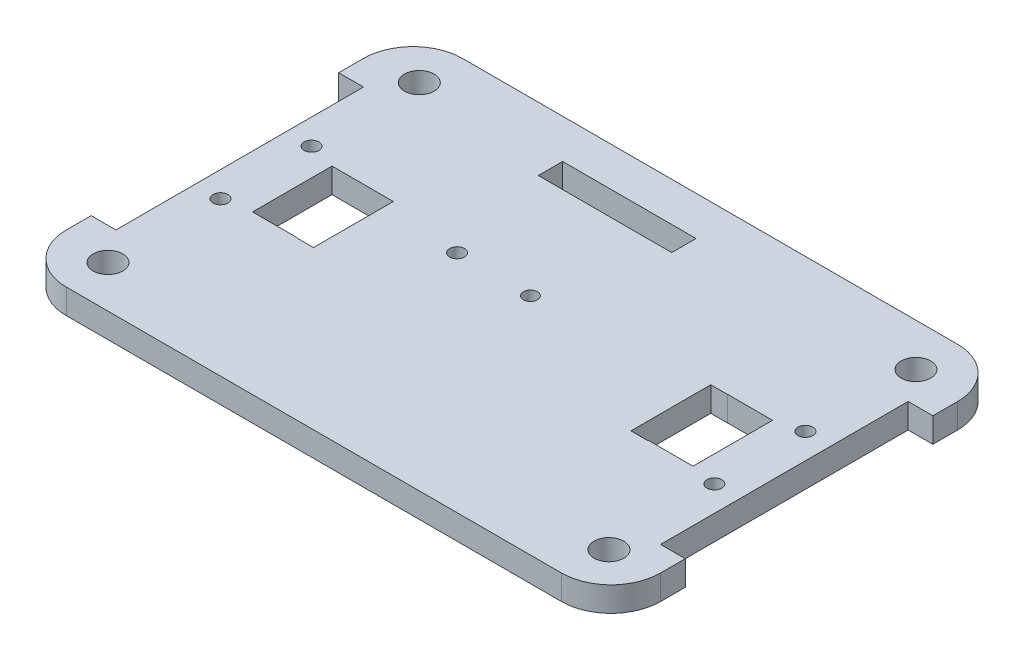
from build123d import *

# Parameters (mm, degrees)
BOSS_EXTRUDE1_DEPTH = 5
SKETCH2_R           = 3
SKETCH2_R_2         = 3.002001364
SKETCH2_R_3         = 2.999925667
SKETCH2_R_4         = 2.998527559
CUT_EXTRUDE2_DEPTH  = 5
SKETCH6_W           = 9.011632363
SKETCH6_H           = 16.045928836
SKETCH6_W_2         = 9.056347314
SKETCH6_H_2         = 16.054931831
CUT_EXTRUDE4_DEPTH  = 5
SKETCH8_R           = 1.49722604
SKETCH8_R_2         = 1.420293569
CUT_EXTRUDE6_DEPTH  = 5
SKETCH16_W          = 26.950881965
SKETCH16_H          = 4.917135509
CUT_EXTRUDE9_DEPTH  = 5
SKETCH11_R          = 1.497426658
SKETCH11_W          = 3.370796783
SKETCH11_H          = 16.122720009
CUT_EXTRUDE10_DEPTH = 10
SKETCH18_W          = 2.969435554
SKETCH18_H          = 16.028197631
CUT_EXTRUDE11_DEPTH = 10


with BuildPart() as part:
    # Sketch1 → Boss-Extrude1 (new body)
    with BuildSketch(Plane(origin=(0, 0, 0), x_dir=(1, 0, 0), z_dir=(0, 1, 0))):
        with BuildLine():
            Line((10, 0), (110, 0))
            ThreePointArc((110, 0), (117.071067812, -2.928932188), (120, -10))
            Line((120, -10), (120, -15))
            Line((120, -15), (115, -15))
            Line((115, -15), (115, -65))
            Line((115, -65), (120, -65))
            Line((120, -65), (120, -70))
            ThreePointArc((120, -70), (117.071067812, -77.071067812), (110, -80))
            Line((110, -80), (10, -80))
            ThreePointArc((10, -80), (2.928932188, -77.071067812), (0, -70))
            Line((0, -70), (0, -65))
            Line((0, -65), (5, -65))
            Line((5, -65), (5, -15))
            Line((5, -15), (0, -15))
            Line((0, -15), (0, -10))
            ThreePointArc((0, -10), (2.928932188, -2.928932188), (10, 0))
        make_face()
    extrude(amount=BOSS_EXTRUDE1_DEPTH)

    # Sketch2 → Cut-Extrude2 (cut)
    with BuildSketch(Plane(origin=(0, 5, 0), x_dir=(1, 0, 0), z_dir=(0, 1, 0))):
        with Locations((9.871405569, -8.58955783)):
            Circle(SKETCH2_R)
        with Locations((9.87978839, -71.481609293)):
            Circle(SKETCH2_R_2)
        with Locations((110.711521692, -71.131223036)):
            Circle(SKETCH2_R_3)
        with Locations((110.199519212, -8.625779617)):
            Circle(SKETCH2_R_4)
    extrude(amount=-CUT_EXTRUDE2_DEPTH, mode=Mode.SUBTRACT)

    # Sketch6 → Cut-Extrude4 (cut)
    with BuildSketch(Plane(origin=(0, 5, 0), x_dir=(1, 0, 0), z_dir=(0, 1, 0))):
        with Locations((20.155698208, -40.027815076)):
            Rectangle(SKETCH6_W, SKETCH6_H)
        with Locations((100.072460304, -40.013270259)):
            Rectangle(SKETCH6_W_2, SKETCH6_H_2)
    extrude(amount=-CUT_EXTRUDE4_DEPTH, mode=Mode.SUBTRACT)

    # Sketch8 → Cut-Extrude6 (cut)
    with BuildSketch(Plane(origin=(0, 5, 0), x_dir=(1, 0, 0), z_dir=(0, 1, 0))):
        with Locations((43.448740086, -34.53592606)):
            Circle(SKETCH8_R)
        with Locations((58.369614813, -34.660876222)):
            Circle(SKETCH8_R_2)
    extrude(amount=-CUT_EXTRUDE6_DEPTH, mode=Mode.SUBTRACT)

    # Sketch16 → Cut-Extrude9 (cut)
    with BuildSketch(Plane(origin=(0, 5, 0), x_dir=(1, 0, 0), z_dir=(0, 1, 0))):
        with Locations((51.607602958, -10.367487293)):
            Rectangle(SKETCH16_W, SKETCH16_H)
    extrude(amount=-CUT_EXTRUDE9_DEPTH, mode=Mode.SUBTRACT)

    # Sketch11 → Cut-Extrude10 (cut)
    with BuildSketch(Plane(origin=(0, 5, 0), x_dir=(1, 0, 0), z_dir=(0, 1, 0))):
        with Locations((10.104440234, -30.597351974)):
            Circle(SKETCH11_R)
        with Locations((10.104440234, -48.982097467)):
            Circle(SKETCH11_R)
        with Locations((109.853007641, -30.597351974)):
            Circle(SKETCH11_R)
        with Locations((109.853007641, -48.982097467)):
            Circle(SKETCH11_R)
        with Locations((93.839893868, -40.073898548)):
            Rectangle(SKETCH11_W, SKETCH11_H)
        with Locations((26.346912782, -40.066210662)):
            Rectangle(SKETCH11_W, SKETCH11_H)
    extrude(amount=-CUT_EXTRUDE10_DEPTH, mode=Mode.SUBTRACT)

    # Sketch18 → Cut-Extrude11 (cut)
    with BuildSketch(Plane(origin=(0, 5, 0), x_dir=(1, 0, 0), z_dir=(0, 1, 0))):
        with Locations((95.940490682, -40.026637359)):
            Rectangle(SKETCH18_W, SKETCH18_H)
    extrude(amount=-CUT_EXTRUDE11_DEPTH, mode=Mode.SUBTRACT)


solid = part.part
